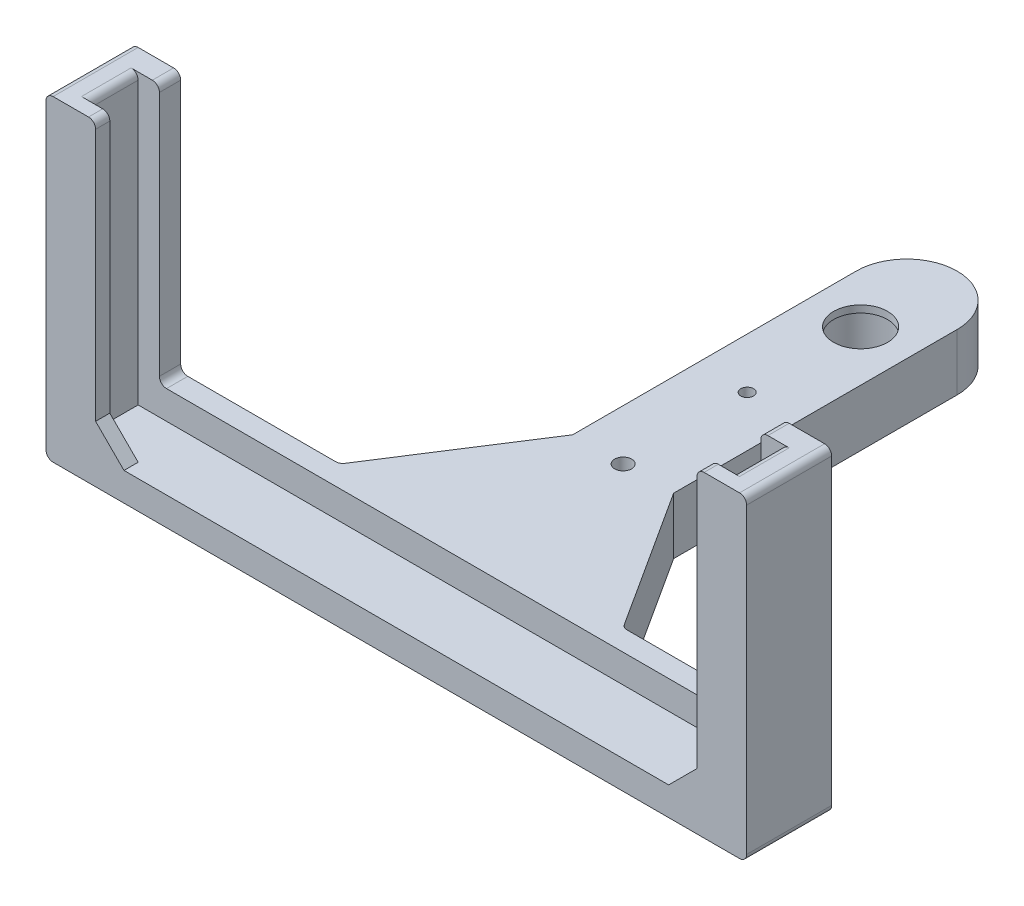
from build123d import *

# Parameters (mm, degrees)
BOSS_EXTRUDE1_DEPTH = 22.34
SKETCH3_W           = 42.42
SKETCH3_H           = 6
CUT_EXTRUDE1_DEPTH  = 20.34
SKETCH4_W           = 45.42
SKETCH4_H           = 3.5
CUT_EXTRUDE2_DEPTH  = 20.34
SKETCH6_R           = 0.6
SKETCH6_R_2         = 0.45
SKETCH6_R_3         = 2.25
BOSS_EXTRUDE2_DEPTH = 4
BOSS_EXTRUDE3_START = 2
SKETCH7_R           = 2.25
SKETCH7_R_2         = 1.9
BOSS_EXTRUDE3_DEPTH = 0.5
SKETCH8_W           = 42.42
SKETCH8_H           = 1.5
BOSS_EXTRUDE4_DEPTH = 2
BOSS_EXTRUDE5_DEPTH = 1
FILLET1_R           = 0.5


with BuildPart() as part:
    # Sketch1 → Boss-Extrude1 (new body)
    with BuildSketch(Plane(origin=(0, 0, 0), x_dir=(1, 0, 0), z_dir=(0, 1, 0))):
        Polygon((47.42, 0), (47.42, 6), (45.42, 6), (0, 6), (-2, 6), (-2, 0), (0, 0), (45.42, 0), align=None)
    extrude(amount=BOSS_EXTRUDE1_DEPTH)

    # Sketch3 → Cut-Extrude1 (cut)
    with BuildSketch(Plane(origin=(0, 22.34, 0), x_dir=(1, 0, 0), z_dir=(0, 1, 0))):
        with Locations((22.71, 3)):
            Rectangle(SKETCH3_W, SKETCH3_H)
    extrude(amount=-CUT_EXTRUDE1_DEPTH, mode=Mode.SUBTRACT)

    # Sketch4 → Cut-Extrude2 (cut)
    with BuildSketch(Plane(origin=(0, 22.34, 0), x_dir=(1, 0, 0), z_dir=(0, 1, 0))):
        with Locations((22.71, 2.75)):
            Rectangle(SKETCH4_W, SKETCH4_H)
    extrude(amount=-CUT_EXTRUDE2_DEPTH, mode=Mode.SUBTRACT)

    # Sketch6 → Boss-Extrude2 (add)
    with BuildSketch(Plane.XZ):
        with BuildLine():
            Line((12.71, -6), (19.146099522, -16))
            Line((19.146099522, -16), (19.146099522, -36))
            ThreePointArc((19.146099522, -36), (22.71, -39.563900478), (26.273900478, -36))
            Line((26.273900478, -36), (26.273900478, -16))
            Line((26.273900478, -16), (32.71, -6))
            Line((32.71, -6), (12.71, -6))
        make_face()
        with Locations((22.71, -16)):
            Circle(SKETCH6_R, mode=Mode.SUBTRACT)
        with Locations((22.71, -24.75)):
            Circle(SKETCH6_R_2, mode=Mode.SUBTRACT)
        with Locations((22.71, -32.75)):
            Circle(SKETCH6_R_3, mode=Mode.SUBTRACT)
    extrude(amount=-BOSS_EXTRUDE2_DEPTH)

    # Sketch7 → Boss-Extrude3 (add)
    with BuildSketch(Plane(origin=(0, 2, 0), x_dir=(1, 0, 0), z_dir=(0, 1, 0)).offset(BOSS_EXTRUDE3_START)):
        with Locations((22.71, 32.75)):
            Circle(SKETCH7_R)
        with Locations((22.71, 32.75)):
            Circle(SKETCH7_R_2, mode=Mode.SUBTRACT)
    extrude(amount=-BOSS_EXTRUDE3_DEPTH)

    # Sketch8 → Boss-Extrude4 (add)
    with BuildSketch(Plane(origin=(0, 2, 0), x_dir=(1, 0, 0), z_dir=(0, 1, 0))):
        with Locations((22.71, 5.25)):
            Rectangle(SKETCH8_W, SKETCH8_H)
    extrude(amount=BOSS_EXTRUDE4_DEPTH)

    # Sketch11 → Boss-Extrude5 (add)
    with BuildSketch(Plane.XY):
        Polygon((1.5, 4), (3.5, 2), (1.5, 2), align=None)
        Polygon((43.92, 4), (41.92, 2), (43.92, 2), align=None)
    extrude(amount=-BOSS_EXTRUDE5_DEPTH)

    # Fillet1
    fillet1_edges = [part.edges().sort_by_distance(p)[0] for p in [
        (1.5, 4, -5.25),
        (43.92, 4, -5.25),
        (47.42, 22.34, -3),
        (-2, 22.34, -3),
        (1.5, 22.34, -5.25),
        (43.92, 22.34, -0.5),
        (1.5, 22.34, -0.5),
        (43.92, 22.34, -5.25),
        (45.42, 22.34, -2.75),
        (0, 22.34, -2.75),
        (12.71, 2, -6),
        (32.71, 2, -6),
        (-2, 0, -3),
        (47.42, 0, -3),
    ]]
    fillet(fillet1_edges, radius=FILLET1_R)


solid = part.part
